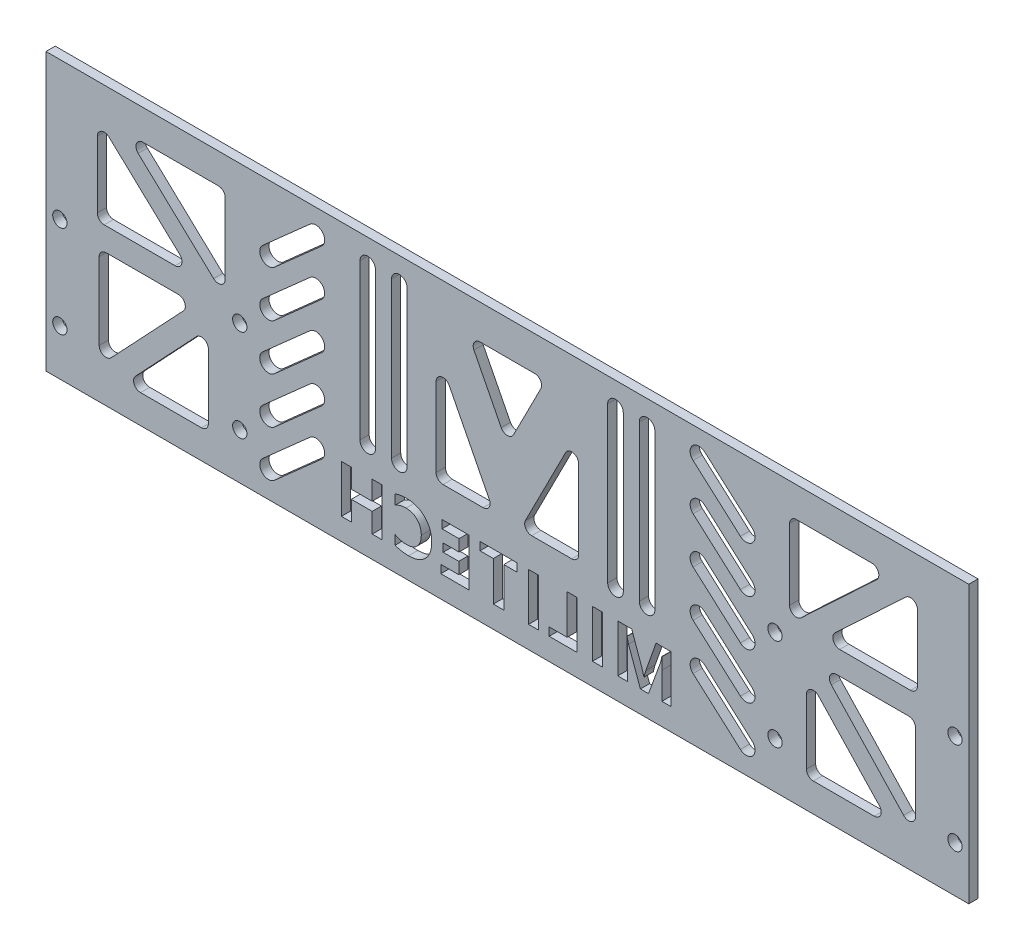
from build123d import *

# Parameters (mm, degrees)
SKETCH_1_R      = 1.55
SKETCH_1_W      = 2.13796744
SKETCH_1_H      = 10.312548828
EXTRUDE_1_DEPTH = 2


with BuildPart() as part:
    # 草图1 → 凸台-拉伸1 (new body)
    with BuildSketch(Plane.XY):
        Polygon((69.118055556, 5.822916667), (69.118055556, -30.177083333), (22.118055556, -30.177083333), (-83.881944444, -30.177083333), (-130.881944444, -30.177083333), (-130.881944444, 5.822916667), (-130.881944444, 29.822916667), (69.118055556, 29.822916667), align=None)
        with Locations((-127.881944444, -0.177083333)):
            Circle(SKETCH_1_R, mode=Mode.SUBTRACT)
        with Locations((-127.881944444, -20.177083333)):
            Circle(SKETCH_1_R, mode=Mode.SUBTRACT)
        with Locations((-88.881944444, -0.177083333)):
            Circle(SKETCH_1_R, mode=Mode.SUBTRACT)
        with Locations((-88.881944444, -20.177083333)):
            Circle(SKETCH_1_R, mode=Mode.SUBTRACT)
        with Locations((27.118055556, -0.177083333)):
            Circle(SKETCH_1_R, mode=Mode.SUBTRACT)
        with Locations((27.118055556, -20.177083333)):
            Circle(SKETCH_1_R, mode=Mode.SUBTRACT)
        with Locations((66.118055556, -0.177083333)):
            Circle(SKETCH_1_R, mode=Mode.SUBTRACT)
        with Locations((66.118055556, -20.177083333)):
            Circle(SKETCH_1_R, mode=Mode.SUBTRACT)
        with BuildLine():
            Line((-24.969688058, 22.330722714), (-36.794200831, 22.330722714))
            ThreePointArc((-36.794200831, 22.330722714), (-38.073161078, 21.614470562), (-38.130710618, 20.149736965))
            Line((-38.130710618, 20.149736965), (-32.218454231, 8.546280469))
            ThreePointArc((-32.218454231, 8.546280469), (-30.881944444, 7.727266218), (-29.545434658, 8.546280469))
            Line((-29.545434658, 8.546280469), (-23.633178271, 20.149736965))
            ThreePointArc((-23.633178271, 20.149736965), (-23.690727811, 21.614470562), (-24.969688058, 22.330722714))
        make_face(mode=Mode.SUBTRACT)
        with BuildLine():
            Line((-46.334451261, 10.151214323), (-46.334451261, -6.936786252))
            ThreePointArc((-46.334451261, -6.936786252), (-45.895111432, -7.997446424), (-44.834451261, -8.436786252))
            Line((-44.834451261, -8.436786252), (-36.127680087, -8.436786252))
            ThreePointArc((-36.127680087, -8.436786252), (-34.84871984, -7.720534099), (-34.791170301, -6.255800502))
            Line((-34.791170301, -6.255800502), (-43.497941474, 10.832200072))
            ThreePointArc((-43.497941474, 10.832200072), (-45.184619306, 11.609769203), (-46.334451261, 10.151214323))
        make_face(mode=Mode.SUBTRACT)
        with BuildLine():
            Line((-16.929437628, -8.436786252), (-25.636208802, -8.436786252))
            ThreePointArc((-25.636208802, -8.436786252), (-26.915169049, -7.720534099), (-26.972718588, -6.255800502))
            Line((-26.972718588, -6.255800502), (-18.265947415, 10.832200072))
            ThreePointArc((-18.265947415, 10.832200072), (-16.579269583, 11.609769203), (-15.429437628, 10.151214323))
            Line((-15.429437628, 10.151214323), (-15.429437628, -6.936786252))
            ThreePointArc((-15.429437628, -6.936786252), (-15.868777457, -7.997446424), (-16.929437628, -8.436786252))
        make_face(mode=Mode.SUBTRACT)
        with BuildLine():
            Line((-52.621473128, 24.566015155), (-52.621473128, -9.073491881))
            ThreePointArc((-52.621473128, -9.073491881), (-54.309832738, -10.761851491), (-55.998192349, -9.073491881))
            Line((-55.998192349, -9.073491881), (-55.998192349, 24.566015155))
            ThreePointArc((-55.998192349, 24.566015155), (-54.309832738, 26.254374765), (-52.621473128, 24.566015155))
        make_face(mode=Mode.SUBTRACT)
        with BuildLine():
            Line((-59.468709325, 24.566015155), (-59.468709325, -9.073491881))
            ThreePointArc((-59.468709325, -9.073491881), (-61.157068936, -10.761851491), (-62.845428546, -9.073491881))
            Line((-62.845428546, -9.073491881), (-62.845428546, 24.566015155))
            ThreePointArc((-62.845428546, 24.566015155), (-61.157068936, 26.254374765), (-59.468709325, 24.566015155))
        make_face(mode=Mode.SUBTRACT)
        with BuildLine():
            Line((-2.295179563, 24.566015155), (-2.295179563, -9.073491881))
            ThreePointArc((-2.295179563, -9.073491881), (-0.606819953, -10.761851491), (1.081539657, -9.073491881))
            Line((1.081539657, -9.073491881), (1.081539657, 24.566015155))
            ThreePointArc((1.081539657, 24.566015155), (-0.606819953, 26.254374765), (-2.295179563, 24.566015155))
        make_face(mode=Mode.SUBTRACT)
        with BuildLine():
            Line((-9.142415761, 24.566015155), (-9.142415761, -9.073491881))
            ThreePointArc((-9.142415761, -9.073491881), (-7.454056151, -10.761851491), (-5.76569654, -9.073491881))
            Line((-5.76569654, -9.073491881), (-5.76569654, 24.566015155))
            ThreePointArc((-5.76569654, 24.566015155), (-7.454056151, 26.254374765), (-9.142415761, 24.566015155))
        make_face(mode=Mode.SUBTRACT)
        with BuildLine():
            Line((-109.883690828, 23.279099238), (-93.534919883, 23.279099238))
            ThreePointArc((-93.534919883, 23.279099238), (-92.474259711, 22.83975941), (-92.034919883, 21.779099238))
            Line((-92.034919883, 21.779099238), (-92.034919883, 6.452126477))
            ThreePointArc((-92.034919883, 6.452126477), (-92.938626138, 5.075742166), (-94.560831576, 5.357820671))
            Line((-94.560831576, 5.357820671), (-110.909602522, 20.684793432))
            ThreePointArc((-110.909602522, 20.684793432), (-111.278584858, 22.330706567), (-109.883690828, 23.279099238))
        make_face(mode=Mode.SUBTRACT)
        with BuildLine():
            Line((-119.75738359, 19.48601931), (-119.75738359, 5.09391798))
            ThreePointArc((-119.75738359, 5.09391798), (-119.318043762, 4.033257809), (-118.25738359, 3.59391798))
            Line((-118.25738359, 3.59391798), (-102.905808839, 3.59391798))
            ThreePointArc((-102.905808839, 3.59391798), (-101.510914809, 4.542310652), (-101.879897145, 6.188223787))
            Line((-101.879897145, 6.188223787), (-117.231471897, 20.580325116))
            ThreePointArc((-117.231471897, 20.580325116), (-118.853677335, 20.862403621), (-119.75738359, 19.48601931))
        make_face(mode=Mode.SUBTRACT)
        with BuildLine():
            Line((-117.853740324, -1.438153982), (-102.184246168, -1.438153982))
            ThreePointArc((-102.184246168, -1.438153982), (-100.807280197, -2.343204645), (-101.091946179, -3.966201031))
            Line((-101.091946179, -3.966201031), (-116.761440335, -20.615038571))
            ThreePointArc((-116.761440335, -20.615038571), (-118.406709589, -20.981346209), (-119.353740324, -19.586991523))
            Line((-119.353740324, -19.586991523), (-119.353740324, -2.938153982))
            ThreePointArc((-119.353740324, -2.938153982), (-118.914400496, -1.87749381), (-117.853740324, -1.438153982))
        make_face(mode=Mode.SUBTRACT)
        with BuildLine():
            Line((-110.400726717, -23.96533578), (-97.191459714, -23.96533578))
            ThreePointArc((-97.191459714, -23.96533578), (-96.130799542, -23.525995952), (-95.691459714, -22.46533578))
            Line((-95.691459714, -22.46533578), (-95.691459714, -8.43048959))
            ThreePointArc((-95.691459714, -8.43048959), (-96.638490449, -7.036134903), (-98.283759703, -7.402442541))
            Line((-98.283759703, -7.402442541), (-111.493026706, -21.437288732))
            ThreePointArc((-111.493026706, -21.437288732), (-111.777692688, -23.060285117), (-110.400726717, -23.96533578))
        make_face(mode=Mode.SUBTRACT)
        with BuildLine():
            Line((49.729137817, -21.437288732), (36.519870814, -7.402442541))
            ThreePointArc((36.519870814, -7.402442541), (34.87460156, -7.036134903), (33.927570825, -8.43048959))
            Line((33.927570825, -8.43048959), (33.927570825, -22.46533578))
            ThreePointArc((33.927570825, -22.46533578), (34.366910653, -23.525995952), (35.427570825, -23.96533578))
            Line((35.427570825, -23.96533578), (48.636837828, -23.96533578))
            ThreePointArc((48.636837828, -23.96533578), (50.013803799, -23.060285117), (49.729137817, -21.437288732))
        make_face(mode=Mode.SUBTRACT)
        with BuildLine():
            Line((57.589851435, -2.938153982), (57.589851435, -19.586991523))
            ThreePointArc((57.589851435, -19.586991523), (56.6428207, -20.981346209), (54.997551446, -20.615038571))
            Line((54.997551446, -20.615038571), (39.32805729, -3.966201031))
            ThreePointArc((39.32805729, -3.966201031), (39.043391308, -2.343204645), (40.420357279, -1.438153982))
            Line((40.420357279, -1.438153982), (56.089851435, -1.438153982))
            ThreePointArc((56.089851435, -1.438153982), (57.150511607, -1.87749381), (57.589851435, -2.938153982))
        make_face(mode=Mode.SUBTRACT)
        with BuildLine():
            Line((49.145713633, 20.684793432), (32.796942687, 5.357820671))
            ThreePointArc((32.796942687, 5.357820671), (31.174737249, 5.075742166), (30.271030994, 6.452126477))
            Line((30.271030994, 6.452126477), (30.271030994, 21.779099238))
            ThreePointArc((30.271030994, 21.779099238), (30.710370822, 22.83975941), (31.771030994, 23.279099238))
            Line((31.771030994, 23.279099238), (48.119801939, 23.279099238))
            ThreePointArc((48.119801939, 23.279099238), (49.514695969, 22.330706567), (49.145713633, 20.684793432))
        make_face(mode=Mode.SUBTRACT)
        with BuildLine():
            Line((55.467583008, 20.580325116), (40.116008256, 6.188223787))
            ThreePointArc((40.116008256, 6.188223787), (39.74702592, 4.542310652), (41.14191995, 3.59391798))
            Line((41.14191995, 3.59391798), (56.493494701, 3.59391798))
            ThreePointArc((56.493494701, 3.59391798), (57.554154873, 4.033257809), (57.993494701, 5.09391798))
            Line((57.993494701, 5.09391798), (57.993494701, 19.48601931))
            ThreePointArc((57.993494701, 19.48601931), (57.089788446, 20.862403621), (55.467583008, 20.580325116))
        make_face(mode=Mode.SUBTRACT)
        with BuildLine():
            Line((-71.129093308, 23.174777254), (-81.38575891, 14.067514444))
            ThreePointArc((-81.38575891, 14.067514444), (-84.074322575, 14.227102029), (-83.914734989, 16.915665694))
            Line((-83.914734989, 16.915665694), (-73.658069388, 26.022928505))
            ThreePointArc((-73.658069388, 26.022928505), (-70.969505723, 25.863340919), (-71.129093308, 23.174777254))
        make_face(mode=Mode.SUBTRACT)
        with BuildLine():
            Line((-71.129093308, 13.174777254), (-81.38575891, 4.067514444))
            ThreePointArc((-81.38575891, 4.067514444), (-84.074322575, 4.227102029), (-83.914734989, 6.915665694))
            Line((-83.914734989, 6.915665694), (-73.658069388, 16.022928505))
            ThreePointArc((-73.658069388, 16.022928505), (-70.969505723, 15.863340919), (-71.129093308, 13.174777254))
        make_face(mode=Mode.SUBTRACT)
        with BuildLine():
            Line((-71.129093308, 3.174777254), (-81.38575891, -5.932485556))
            ThreePointArc((-81.38575891, -5.932485556), (-84.074322575, -5.772897971), (-83.914734989, -3.084334306))
            Line((-83.914734989, -3.084334306), (-73.658069388, 6.022928505))
            ThreePointArc((-73.658069388, 6.022928505), (-70.969505723, 5.863340919), (-71.129093308, 3.174777254))
        make_face(mode=Mode.SUBTRACT)
        with BuildLine():
            Line((-71.129093308, -6.825222746), (-81.38575891, -15.932485556))
            ThreePointArc((-81.38575891, -15.932485556), (-84.074322575, -15.772897971), (-83.914734989, -13.084334306))
            Line((-83.914734989, -13.084334306), (-73.658069388, -3.977071495))
            ThreePointArc((-73.658069388, -3.977071495), (-70.969505723, -4.136659081), (-71.129093308, -6.825222746))
        make_face(mode=Mode.SUBTRACT)
        with BuildLine():
            Line((-71.129093308, -16.825222746), (-81.38575891, -25.932485556))
            ThreePointArc((-81.38575891, -25.932485556), (-84.074322575, -25.772897971), (-83.914734989, -23.084334306))
            Line((-83.914734989, -23.084334306), (-73.658069388, -13.977071495))
            ThreePointArc((-73.658069388, -13.977071495), (-70.969505723, -14.136659081), (-71.129093308, -16.825222746))
        make_face(mode=Mode.SUBTRACT)
        with BuildLine():
            Line((9.36520442, -16.825222746), (19.621870021, -25.932485556))
            ThreePointArc((19.621870021, -25.932485556), (22.310433686, -25.772897971), (22.150846101, -23.084334306))
            Line((22.150846101, -23.084334306), (11.894180499, -13.977071495))
            ThreePointArc((11.894180499, -13.977071495), (9.205616834, -14.136659081), (9.36520442, -16.825222746))
        make_face(mode=Mode.SUBTRACT)
        with BuildLine():
            Line((9.36520442, -6.825222746), (19.621870021, -15.932485556))
            ThreePointArc((19.621870021, -15.932485556), (22.310433686, -15.772897971), (22.150846101, -13.084334306))
            Line((22.150846101, -13.084334306), (11.894180499, -3.977071495))
            ThreePointArc((11.894180499, -3.977071495), (9.205616834, -4.136659081), (9.36520442, -6.825222746))
        make_face(mode=Mode.SUBTRACT)
        with BuildLine():
            Line((9.36520442, 3.174777254), (19.621870021, -5.932485556))
            ThreePointArc((19.621870021, -5.932485556), (22.310433686, -5.772897971), (22.150846101, -3.084334306))
            Line((22.150846101, -3.084334306), (11.894180499, 6.022928505))
            ThreePointArc((11.894180499, 6.022928505), (9.205616834, 5.863340919), (9.36520442, 3.174777254))
        make_face(mode=Mode.SUBTRACT)
        with BuildLine():
            Line((9.36520442, 13.174777254), (19.621870021, 4.067514444))
            ThreePointArc((19.621870021, 4.067514444), (22.310433686, 4.227102029), (22.150846101, 6.915665694))
            Line((22.150846101, 6.915665694), (11.894180499, 16.022928505))
            ThreePointArc((11.894180499, 16.022928505), (9.205616834, 15.863340919), (9.36520442, 13.174777254))
        make_face(mode=Mode.SUBTRACT)
        with BuildLine():
            Line((9.36520442, 23.174777254), (19.621870021, 14.067514444))
            ThreePointArc((19.621870021, 14.067514444), (22.310433686, 14.227102029), (22.150846101, 16.915665694))
            Line((22.150846101, 16.915665694), (11.894180499, 26.022928505))
            ThreePointArc((11.894180499, 26.022928505), (9.205616834, 25.863340919), (9.36520442, 23.174777254))
        make_face(mode=Mode.SUBTRACT)
        with BuildLine():
            Line((-4.821838116, -25.422085063), (-4.821838116, -19.171281362))
            add(Edge.make_bspline(
                [(-4.821838116, -19.171281362), (-4.821898862, -19.096595556), (-4.822023604, -18.943227926), (-4.833851107, -18.706157476), (-4.846648712, -18.45518494), (-4.866543993, -18.189857826), (-4.89297113, -17.910949164), (-4.921073146, -17.617841608), (-4.95985305, -17.311582784), (-4.986854331, -17.102737477), (-5.000657084, -16.995978093)],
                knots=[0, 0, 0, 0, 0.000224024, 0.000460033, 0.000711935, 0.000977943, 0.001258146, 0.001552417, 0.001861229, 0.002184179, 0.002184179, 0.002184179, 0.002184179], degree=3))
            Line((-5.000657084, -16.995978093), (-4.947600906, -16.995978093))
            add(Edge.make_bspline(
                [(-4.947600906, -16.995978093), (-4.931481812, -17.075289518), (-4.900674498, -17.226871971), (-4.852483213, -17.443321538), (-4.810328768, -17.639563971), (-4.768685549, -17.815039303), (-4.729866387, -17.97043812), (-4.692157362, -18.10509487), (-4.660017881, -18.219711585), (-4.636114086, -18.287762344), (-4.625333755, -18.318452438)],
                knots=[0, 0, 0, 0, 0.000242792, 0.000464032, 0.000665236, 0.000844927, 0.001005063, 0.001145698, 0.001264465, 0.001362027, 0.001362027, 0.001362027, 0.001362027], degree=3))
            Line((-4.625333755, -18.318452438), (-2.055056723, -25.422085063))
            Line((-2.055056723, -25.422085063), (-0.294377655, -25.422085063))
            Line((-0.294377655, -25.422085063), (2.273934334, -18.385263921))
            add(Edge.make_bspline(
                [(2.273934334, -18.385263921), (2.282683288, -18.359791834), (2.303154751, -18.300190323), (2.331738259, -18.195684986), (2.364776631, -18.063115166), (2.40453852, -17.903687821), (2.444938491, -17.715189694), (2.491703449, -17.50026559), (2.546267006, -17.257849515), (2.580234916, -17.086456322), (2.598166529, -16.995978093)],
                knots=[0, 0, 0, 0, 8.0782e-05, 0.00018902, 0.00032485, 0.000490707, 0.000681893, 0.000903133, 0.001150588, 0.001427289, 0.001427289, 0.001427289, 0.001427289], degree=3))
            Line((2.598166529, -16.995978093), (2.657117837, -16.995978093))
            add(Edge.make_bspline(
                [(2.657117837, -16.995978093), (2.639432603, -17.428883277), (2.604045104, -18.295110565), (2.600126682, -19.16205162), (2.598166529, -19.59573078)],
                knots=[0, 0, 0, 0, 0.00129968, 0.002600611, 0.002600611, 0.002600611, 0.002600611], degree=3))
            Line((2.598166529, -19.59573078), (2.598166529, -25.422085063))
            Line((2.598166529, -25.422085063), (4.610371178, -25.422085063))
            Line((4.610371178, -25.422085063), (4.610371178, -15.109536235))
            Line((4.610371178, -15.109536235), (1.340538623, -15.109536235))
            Line((1.340538623, -15.109536235), (-0.862275256, -21.342654543))
            add(Edge.make_bspline(
                [(-0.862275256, -21.342654543), (-0.905937089, -21.469375615), (-0.991135511, -21.716649592), (-1.097986401, -22.085507745), (-1.181486299, -22.443048111), (-1.220491739, -22.679303574), (-1.239563628, -22.794821766)],
                knots=[0, 0, 0, 0, 0.000402047, 0.000784525, 0.001151562, 0.001502733, 0.001502733, 0.001502733, 0.001502733], degree=3))
            Line((-1.239563628, -22.794821766), (-1.284759631, -22.794821766))
            add(Edge.make_bspline(
                [(-1.284759631, -22.794821766), (-1.318781338, -22.658394066), (-1.384721289, -22.393973593), (-1.491632928, -22.013734128), (-1.595863107, -21.660185453), (-1.67365046, -21.436703902), (-1.711174092, -21.328899238)],
                knots=[0, 0, 0, 0, 0.000421789, 0.0008175, 0.0011849, 0.001527298, 0.001527298, 0.001527298, 0.001527298], degree=3))
            Line((-1.711174092, -21.328899238), (-3.941498582, -15.109536235))
            Line((-3.941498582, -15.109536235), (-6.959805556, -15.109536235))
            Line((-6.959805556, -15.109536235), (-6.959805556, -25.422085063))
            Line((-6.959805556, -25.422085063), (-4.821838116, -25.422085063))
        make_face(mode=Mode.SUBTRACT)
        with Locations((-11.374079505, -20.265810649)):
            Rectangle(SKETCH_1_W, SKETCH_1_H, mode=Mode.SUBTRACT)
        Polygon((-21.824967403, -25.422085063), (-15.788353455, -25.422085063), (-15.788353455, -15.109536235), (-17.926320895, -15.109536235), (-17.926320895, -23.661405995), (-21.824967403, -23.661405995), align=None, mode=Mode.SUBTRACT)
        with Locations((-25.233139028, -20.265810649)):
            Rectangle(SKETCH_1_W, SKETCH_1_H, mode=Mode.SUBTRACT)
        Polygon((-36.815892041, -16.870215303), (-33.923347858, -16.870215303), (-33.923347858, -25.422085063), (-31.659617627, -25.422085063), (-31.659617627, -16.870215303), (-28.767073444, -16.870215303), (-28.767073444, -15.109536235), (-36.815892041, -15.109536235), align=None, mode=Mode.SUBTRACT)
        Polygon((-45.317456685, -25.422085063), (-39.155079946, -25.422085063), (-39.155079946, -15.109536235), (-45.065931104, -15.109536235), (-45.065931104, -16.870215303), (-41.373614174, -16.870215303), (-41.373614174, -19.385471115), (-44.814405522, -19.385471115), (-44.814405522, -21.146150183), (-41.418810177, -21.146150183), (-41.418810177, -23.661405995), (-45.317456685, -23.661405995), align=None, mode=Mode.SUBTRACT)
        with BuildLine():
            add(Edge.make_bspline(
                [(-55.202412025, -25.007460863), (-55.106718163, -25.050837687), (-54.910971689, -25.139567102), (-54.598928855, -25.247762463), (-54.267411876, -25.343038894), (-53.913081269, -25.416487251), (-53.538558089, -25.474933412), (-53.143216586, -25.518092061), (-52.726810513, -25.544068429), (-52.442219325, -25.546565749), (-52.296112536, -25.547847853)],
                knots=[0, 0, 0, 0, 0.000315051, 0.000644452, 0.00098968, 0.001349261, 0.001729186, 0.002126519, 0.002541929, 0.002980204, 0.002980204, 0.002980204, 0.002980204], degree=3))
            add(Edge.make_bspline(
                [(-52.296112536, -25.547847853), (-52.108586544, -25.543890216), (-51.74218952, -25.536157598), (-51.208096082, -25.470275776), (-50.703478245, -25.362451193), (-50.228115788, -25.212084235), (-49.783176542, -25.01524976), (-49.365373727, -24.780218984), (-48.980367887, -24.496173959), (-48.627339734, -24.17266165), (-48.310709884, -23.812720613), (-48.034713947, -23.421744208), (-47.798941243, -23.002871277), (-47.607783175, -22.554006522), (-47.461198783, -22.076169676), (-47.354953936, -21.570531311), (-47.291666087, -21.036407075), (-47.283519499, -20.670781817), (-47.279356218, -20.483930489)],
                knots=[0, 0, 0, 0, 0.000562418, 0.001098879, 0.001611488, 0.002108647, 0.002591689, 0.003068676, 0.003543851, 0.00402368, 0.004502643, 0.004979157, 0.005456889, 0.005941972, 0.006439827, 0.006953948, 0.007490174, 0.008050629, 0.008050629, 0.008050629, 0.008050629], degree=3))
            add(Edge.make_bspline(
                [(-47.279356218, -20.483930489), (-47.283667424, -20.286544444), (-47.292118239, -19.89962882), (-47.364843777, -19.333411059), (-47.481051224, -18.793893985), (-47.649752838, -18.283078252), (-47.861548154, -17.798886279), (-48.123365317, -17.34314373), (-48.433425136, -16.916054512), (-48.78619544, -16.518586612), (-49.174917173, -16.15700074), (-49.59796329, -15.84427171), (-50.046361183, -15.575551751), (-50.524540099, -15.360290907), (-51.028352415, -15.189416594), (-51.560691685, -15.071105184), (-52.119733091, -14.996114521), (-52.502196989, -14.987937769), (-52.696981431, -14.983773444)],
                knots=[0, 0, 0, 0, 0.000591948, 0.001160335, 0.001709595, 0.002245249, 0.002771386, 0.003292489, 0.003818805, 0.004351941, 0.004884526, 0.005408412, 0.005927399, 0.006449761, 0.006978577, 0.007520594, 0.008083382, 0.008667477, 0.008667477, 0.008667477, 0.008667477], degree=3))
            add(Edge.make_bspline(
                [(-52.696981431, -14.983773444), (-52.819487251, -14.984896657), (-53.058736828, -14.987090253), (-53.410180751, -15.004477027), (-53.746384154, -15.03631233), (-54.067749212, -15.078714589), (-54.373906872, -15.134136167), (-54.664832013, -15.20004878), (-54.940515081, -15.280089149), (-55.116293571, -15.344987013), (-55.202412025, -15.376782165)],
                knots=[0, 0, 0, 0, 0.00036751, 0.000717735, 0.001055225, 0.001380379, 0.001689891, 0.001988293, 0.002274953, 0.002550291, 0.002550291, 0.002550291, 0.002550291], degree=3))
            Line((-55.202412025, -15.376782165), (-55.202412025, -17.499029256))
            add(Edge.make_bspline(
                [(-55.202412025, -17.499029256), (-55.115366407, -17.448541518), (-54.941339793, -17.347603523), (-54.666853534, -17.22051108), (-54.384343009, -17.112773162), (-54.093662083, -17.023490654), (-53.794174274, -16.954751556), (-53.485582459, -16.90613711), (-53.168548868, -16.875711225), (-52.954470568, -16.872059861), (-52.846324745, -16.870215303)],
                knots=[0, 0, 0, 0, 0.000301754, 0.000603284, 0.000906188, 0.001208281, 0.001514784, 0.001827183, 0.002144925, 0.002469306, 0.002469306, 0.002469306, 0.002469306], degree=3))
            add(Edge.make_bspline(
                [(-52.846324745, -16.870215303), (-52.724366574, -16.873446507), (-52.485566414, -16.879773366), (-52.13605705, -16.923113764), (-51.805019077, -16.996478345), (-51.494482044, -17.104653675), (-51.200862921, -17.23776858), (-50.927010933, -17.403933779), (-50.671902444, -17.599551794), (-50.43893813, -17.823759468), (-50.228402838, -18.070981319), (-50.045515992, -18.339501927), (-49.888742077, -18.625294555), (-49.764132515, -18.930569326), (-49.661264318, -19.251832336), (-49.595779615, -19.593681674), (-49.549665313, -19.952767385), (-49.545313414, -20.198840653), (-49.543086448, -20.324761957)],
                knots=[0, 0, 0, 0, 0.000365836, 0.000716325, 0.001054792, 0.001381043, 0.001701097, 0.00202024, 0.002339776, 0.002663603, 0.00298843, 0.003312185, 0.003636662, 0.003964371, 0.004299985, 0.004646825, 0.005007066, 0.005384605, 0.005384605, 0.005384605, 0.005384605], degree=3))
            add(Edge.make_bspline(
                [(-49.543086448, -20.324761957), (-49.545757537, -20.447357887), (-49.550971183, -20.686650517), (-49.590773665, -21.036419862), (-49.656558461, -21.367529757), (-49.752210094, -21.680213449), (-49.87127636, -21.97551347), (-50.017692095, -22.252990676), (-50.191093169, -22.511588131), (-50.39162079, -22.749270457), (-50.615336826, -22.96290315), (-50.857781994, -23.150850447), (-51.11962762, -23.310314205), (-51.401665991, -23.436581743), (-51.701493417, -23.538357037), (-52.020193754, -23.610104374), (-52.357742477, -23.654402466), (-52.588764174, -23.659037622), (-52.706806649, -23.661405995)],
                knots=[0, 0, 0, 0, 0.000367721, 0.000717747, 0.001054567, 0.001379055, 0.001697252, 0.002008425, 0.002318535, 0.002629515, 0.00293945, 0.003244849, 0.003548154, 0.003856822, 0.004170011, 0.004496545, 0.004835337, 0.005189312, 0.005189312, 0.005189312, 0.005189312], degree=3))
            add(Edge.make_bspline(
                [(-52.706806649, -23.661405995), (-52.819531895, -23.659530521), (-53.043404712, -23.655805822), (-53.374852614, -23.625672609), (-53.699032682, -23.576472173), (-54.015459867, -23.507825734), (-54.32469261, -23.419338546), (-54.625859592, -23.310776017), (-54.919859156, -23.183772679), (-55.108095331, -23.083056431), (-55.202412025, -23.032592042)],
                knots=[0, 0, 0, 0, 0.00033813, 0.000671528, 0.000997518, 0.00132128, 0.001642214, 0.001961701, 0.00228114, 0.00260193, 0.00260193, 0.00260193, 0.00260193], degree=3))
            Line((-55.202412025, -23.032592042), (-55.202412025, -25.007460863))
        make_face(mode=Mode.SUBTRACT)
        Polygon((-66.848046433, -25.422085063), (-64.710078993, -25.422085063), (-64.710078993, -21.146150183), (-60.182618532, -21.146150183), (-60.182618532, -25.422085063), (-58.044651092, -25.422085063), (-58.044651092, -15.109536235), (-60.182618532, -15.109536235), (-60.182618532, -19.259708324), (-64.710078993, -19.259708324), (-64.710078993, -15.109536235), (-66.848046433, -15.109536235), align=None, mode=Mode.SUBTRACT)
    extrude(amount=EXTRUDE_1_DEPTH)


solid = part.part
